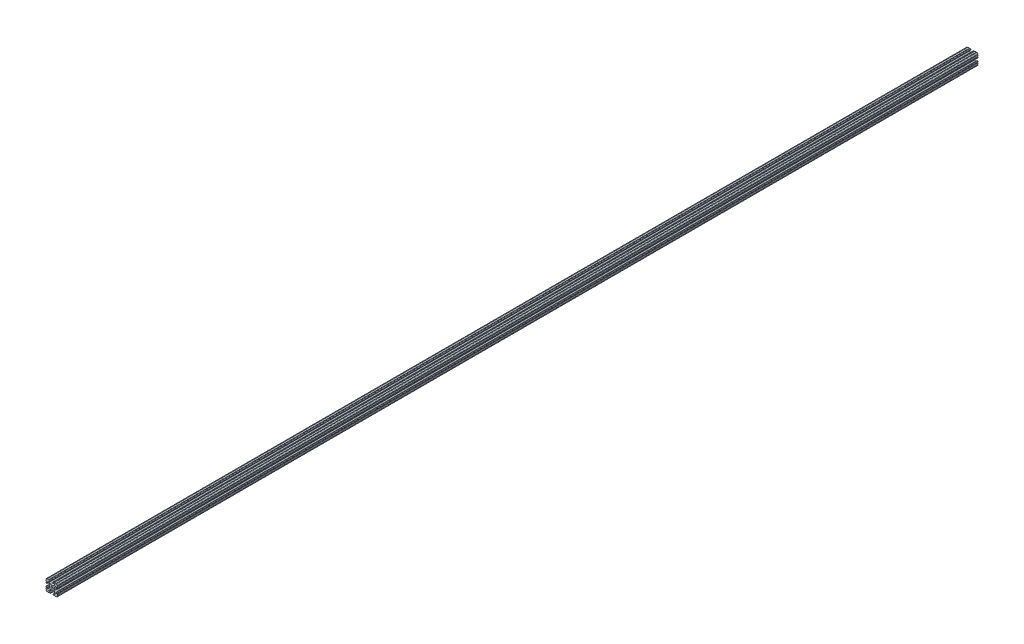
from build123d import *

# Parameters (mm, degrees)
BOSS_EXTRUDE1_DEPTH     = 1524
SKETCH5_R               = 1.016
CUT_EXTRUDE1_DEPTH      = 1525
CUT_EXTRUDE1_DEPTH_BACK = 1525


with BuildPart() as part:
    # Sketch4 → Boss-Extrude1 (new body, symmetric)
    with BuildSketch(Plane.XY):
        with BuildLine():
            Line((5.7912, -19.05), (14.3002, -19.05))
            ThreePointArc((14.3002, -19.05), (17.658815789, -17.658815789), (19.05, -14.3002))
            Line((19.05, -14.3002), (19.05, -5.7912))
            ThreePointArc((19.05, -5.7912), (18.544114832, -4.569885168), (17.3228, -4.064))
            Line((17.3228, -4.064), (16.7132, -4.064))
            ThreePointArc((16.7132, -4.064), (15.491885168, -4.569885168), (14.986, -5.7912))
            Line((14.986, -5.7912), (14.986, -8.996305235))
            ThreePointArc((14.986, -8.996305235), (14.189232738, -10.188751711), (12.782646215, -9.908964256))
            Line((12.782646215, -9.908964256), (7.888897763, -5.015215804))
            ThreePointArc((7.888897763, -5.015215804), (7.219915375, -4.014012907), (6.985, -2.833013566))
            Line((6.985, -2.833013566), (6.985, 0))
            Line((6.985, 0), (3.3274, 0))
            ThreePointArc((3.3274, 0), (2.352827104, -2.352827104), (0, -3.3274))
            Line((0, -3.3274), (0, -6.985))
            Line((0, -6.985), (2.833013566, -6.985))
            ThreePointArc((2.833013566, -6.985), (4.014012907, -7.219915375), (5.015215804, -7.888897763))
            Line((5.015215804, -7.888897763), (9.908964256, -12.782646215))
            ThreePointArc((9.908964256, -12.782646215), (10.188751711, -14.189232738), (8.996305235, -14.986))
            Line((8.996305235, -14.986), (5.7912, -14.986))
            ThreePointArc((5.7912, -14.986), (4.569885168, -15.491885168), (4.064, -16.7132))
            Line((4.064, -16.7132), (4.064, -17.3228))
            ThreePointArc((4.064, -17.3228), (4.569885168, -18.544114832), (5.7912, -19.05))
        make_face()
    extrude(amount=BOSS_EXTRUDE1_DEPTH, both=True)

    # Sketch5 → Cut-Extrude1 (cut, two sides)
    with BuildSketch(Plane.XY) as cut_extrude1_sk:
        with Locations((14.739477062, -19.05)):
            Circle(SKETCH5_R)
        with Locations((7.980305235, -19.05)):
            Circle(SKETCH5_R)
        with Locations((19.05, -14.739477062)):
            Circle(SKETCH5_R)
        with Locations((19.05, -7.980305235)):
            Circle(SKETCH5_R)
    extrude(amount=CUT_EXTRUDE1_DEPTH, mode=Mode.SUBTRACT)
    extrude(cut_extrude1_sk.sketch, amount=-CUT_EXTRUDE1_DEPTH_BACK, mode=Mode.SUBTRACT)

    # Mirror1: part across plane


with BuildPart() as part_1:
    add(part.part)
    add(part.part.mirror(Plane(origin=(0, 0, 0), x_dir=(0, 0, 1), z_dir=(1, 0, 0))))

    # Mirror2: part across plane


with BuildPart() as part_2:
    add(part_1.part)
    add(part_1.part.mirror(Plane.ZX))


solid = part_2.part
